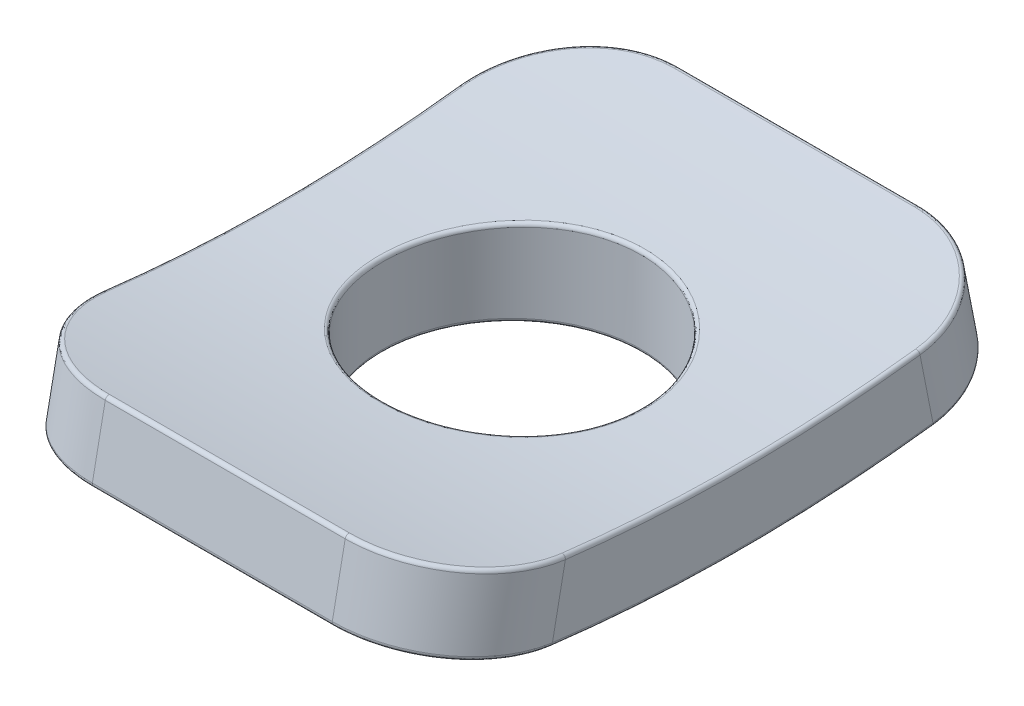
from build123d import *

# Parameters (mm, degrees)
BOSS_EXTRUDE1_DEPTH     = 6.25
FILLET1_R               = 3
CUT_EXTRUDE1_DEPTH      = 11.453774894
CUT_EXTRUDE1_DEPTH_BACK = 11.453774894
SKETCH2_R               = 3.5
BOSS_EXTRUDE2_REACH     = 14.704
BOSS_EXTRUDE2_START     = -2.25
SKETCH2_3_R             = 6
SKETCH2_3_R_2           = 3.5
FILLET2_R               = 0.1


with BuildPart() as part:
    # Sketch1 → Boss-Extrude1 (new, symmetric)
    with BuildSketch(Plane(origin=(0, 0, 0), x_dir=(0, 0, -1), z_dir=(1, 0, 0))):
        with BuildLine():
            Line((-7.75, 0.757962591), (-8.1375, -1.204139279))
            ThreePointArc((-8.1375, -1.204139279), (0, -2), (8.1375, -1.204139279))
            Line((8.1375, -1.204139279), (7.75, 0.757962591))
            ThreePointArc((7.75, 0.757962591), (0, 0), (-7.75, 0.757962591))
        make_face()
    extrude(amount=BOSS_EXTRUDE1_DEPTH, both=True)

    # Fillet1
    fillet1_edges = [part.edges().sort_by_distance(p)[0] for p in [
        (-6.25, -0.223088344, 7.94375),
        (-6.25, -0.223088344, -7.94375),
        (6.25, -0.223088344, -7.94375),
        (6.25, -0.223088344, 7.94375),
    ]]
    fillet(fillet1_edges, radius=FILLET1_R)

    # Sketch2 → Cut-Extrude1 (cut, two sides: drawn at the far end of the back side and taken through both)
    with BuildSketch(Plane(origin=(0, 0, 0), x_dir=(1, 0, 0), z_dir=(0, 1, 0)).offset(-CUT_EXTRUDE1_DEPTH_BACK)):
        Circle(SKETCH2_R)
    extrude(amount=CUT_EXTRUDE1_DEPTH + CUT_EXTRUDE1_DEPTH_BACK, mode=Mode.SUBTRACT)

    # Sketch2_3 → Boss-Extrude2 (add, up to next)
    with BuildSketch(Plane(origin=(0, 0, 0), x_dir=(1, 0, 0), z_dir=(0, 1, 0)).offset(BOSS_EXTRUDE2_START), mode=Mode.PRIVATE) as boss_extrude2_sk1:
        Circle(SKETCH2_3_R)
        Circle(SKETCH2_3_R_2, mode=Mode.SUBTRACT)
    boss_extrude2_tool1 = extrude(boss_extrude2_sk1.sketch, amount=BOSS_EXTRUDE2_REACH, mode=Mode.PRIVATE) - part.part
    add(boss_extrude2_tool1.solids().sort_by_distance((-5.830294, -2.25, 0))[0])

    # Fillet2
    fillet2_edges = [part.edges().sort_by_distance(p)[0] for p in [
        (-3.5, -2.25, 0),
        (-3.499999993, 3.7e-08, -1e-09),
        (-6.25, 0, 0),
        (-6.25, -2, 0),
        (6.25, 0, 0),
        (6.25, -2, 0),
        (0, 0.757962591, -7.75),
        (0, -1.204139279, 8.1375),
        (0, 0.757962591, 7.75),
        (5.37214674, -1.365508435, 7.272875061),
        (5.372146702, -1.365508427, -7.272875132),
        (-5.372146685, -1.365508429, -7.272875111),
        (-5.37214674, -1.365508435, 7.272875061),
        (5.372231621, 0.597030679, 6.885202181),
        (5.372231707, 0.597030658, -6.88520203),
        (-5.372231709, 0.597030661, -6.885202032),
        (-5.372231621, 0.597030679, 6.885202181),
        (-6, -2.25, 0),
        (0, -1.204139279, -8.1375),
    ]]
    fillet(fillet2_edges, radius=FILLET2_R)


solid = part.part
